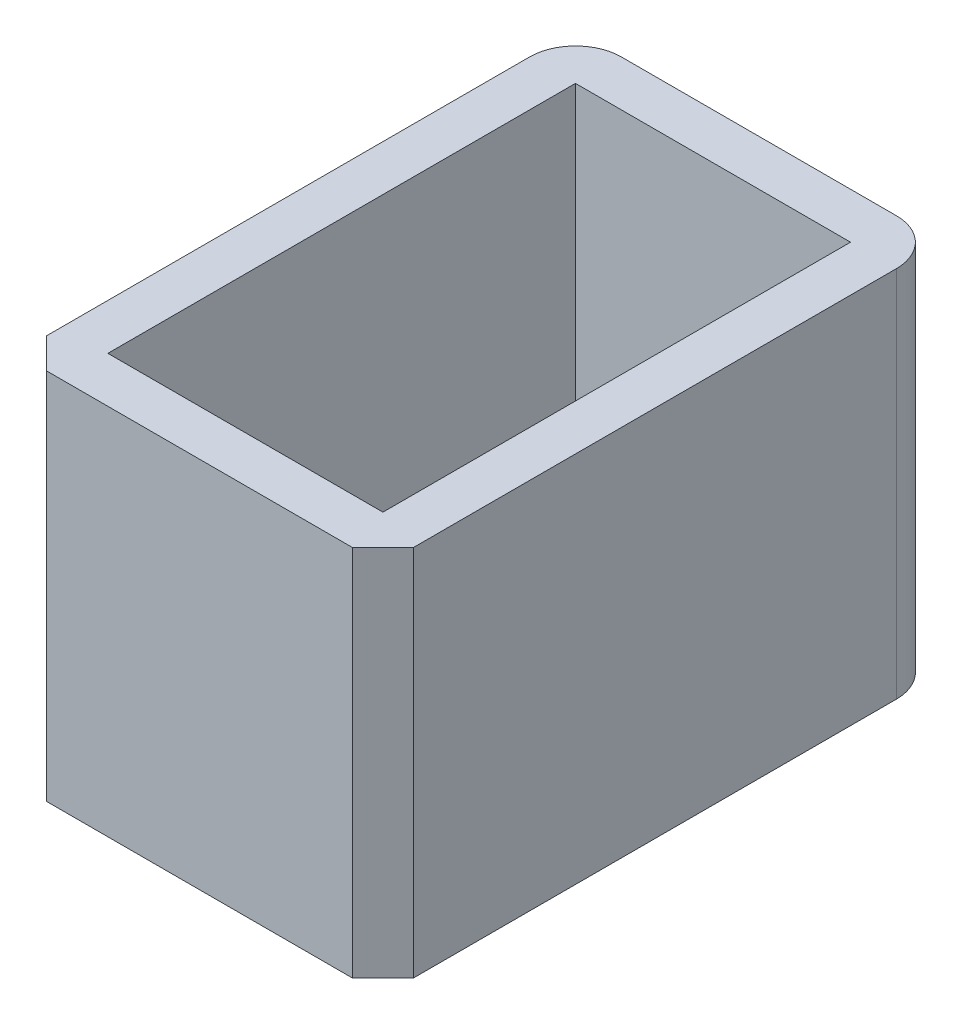
from build123d import *

# Parameters (mm, degrees)
SKETCH1_W           = 24
SKETCH1_H           = 36.6
BOSS_EXTRUDE1_DEPTH = 24.4
SKETCH2_W           = 18
SKETCH2_H           = 30.6
CUT_EXTRUDE1_DEPTH  = 24.4
FILLET2_R           = 3
CHAMFER1_SIZE       = 2


with BuildPart() as part:
    # Sketch1 → Boss-Extrude1 (new body)
    with BuildSketch(Plane(origin=(0, 0, 0), x_dir=(1, 0, 0), z_dir=(0, 1, 0))):
        with Locations((12, 18.3)):
            Rectangle(SKETCH1_W, SKETCH1_H)
    extrude(amount=BOSS_EXTRUDE1_DEPTH)

    # Sketch2 → Cut-Extrude1 (cut)
    with BuildSketch(Plane(origin=(0, 24.4, 0), x_dir=(1, 0, 0), z_dir=(0, 1, 0))):
        with Locations((12, 18.3)):
            Rectangle(SKETCH2_W, SKETCH2_H)
    extrude(amount=-CUT_EXTRUDE1_DEPTH, mode=Mode.SUBTRACT)

    # Fillet2
    fillet2_edges = [part.edges().sort_by_distance(p)[0] for p in [
        (0, 12.2, -36.6),
        (24, 12.2, -36.6),
    ]]
    fillet(fillet2_edges, radius=FILLET2_R)

    # Chamfer1
    chamfer1_edges = [part.edges().sort_by_distance(p)[0] for p in [
        (24, 12.2, 0),
        (0, 12.2, 0),
    ]]
    chamfer(chamfer1_edges, length=CHAMFER1_SIZE)


solid = part.part
